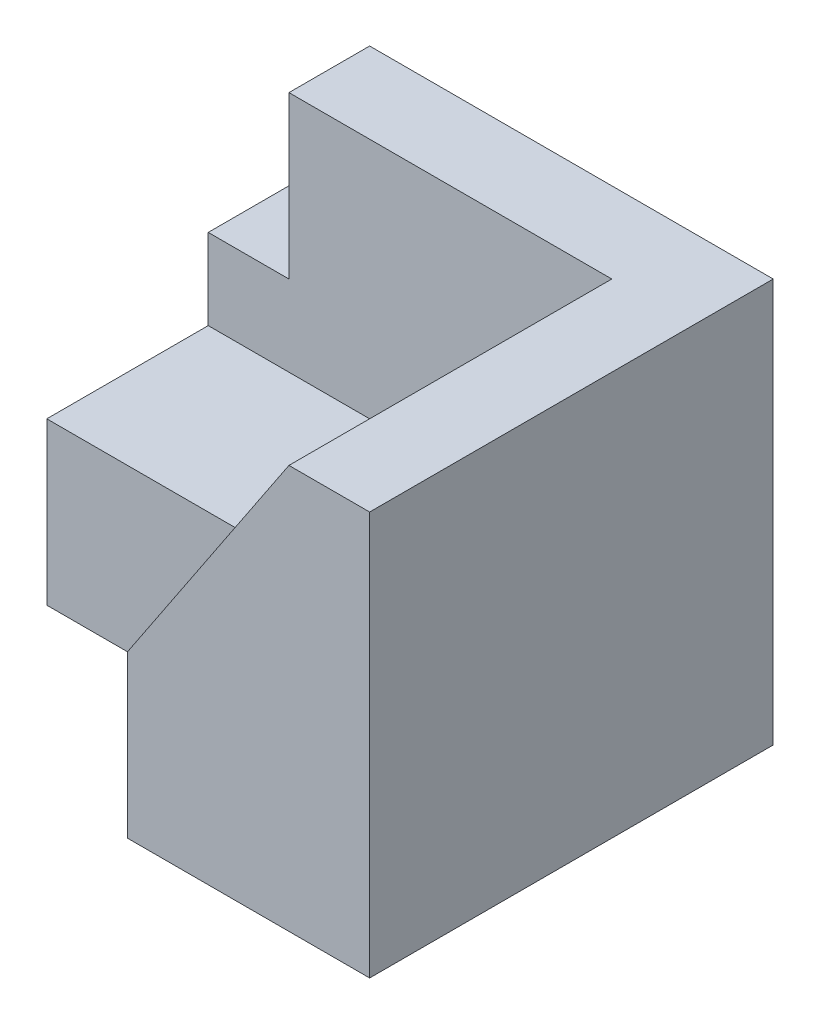
from build123d import *

# Parameters (mm, degrees)
SKETCH1_W           = 60
SKETCH1_H           = 50
BOSS_EXTRUDE2_DEPTH = 50
SKETCH2_W           = 10
SKETCH2_H           = 20
CUT_EXTRUDE1_DEPTH  = 50
SKETCH3_W           = 30
SKETCH3_H           = 20
CUT_EXTRUDE2_DEPTH  = 20
CUT_EXTRUDE4_DEPTH  = 40


with BuildPart() as part:
    # Sketch1 → Boss-Extrude2 (new body)
    with BuildSketch(Plane.XY):
        with Locations((30, 25)):
            Rectangle(SKETCH1_W, SKETCH1_H)
    extrude(amount=BOSS_EXTRUDE2_DEPTH)

    # Sketch2 → Cut-Extrude1 (cut)
    with BuildSketch(Plane.XY.offset(50)):
        with Locations((5, 40)):
            Rectangle(SKETCH2_W, SKETCH2_H)
    extrude(amount=-CUT_EXTRUDE1_DEPTH, mode=Mode.SUBTRACT)

    # Sketch3 → Cut-Extrude2 (cut)
    with BuildSketch(Plane.XY.offset(50)):
        with Locations((15, 10)):
            Rectangle(SKETCH3_W, SKETCH3_H)
    extrude(amount=-CUT_EXTRUDE2_DEPTH, mode=Mode.SUBTRACT)

    # Sketch4 → Cut-Extrude4 (cut)
    with BuildSketch(Plane.XY.offset(50)):
        Polygon((30, 20), (50, 50), (10, 50), (10, 30), (0, 30), (0, 20), align=None)
    extrude(amount=-CUT_EXTRUDE4_DEPTH, mode=Mode.SUBTRACT)


solid = part.part
